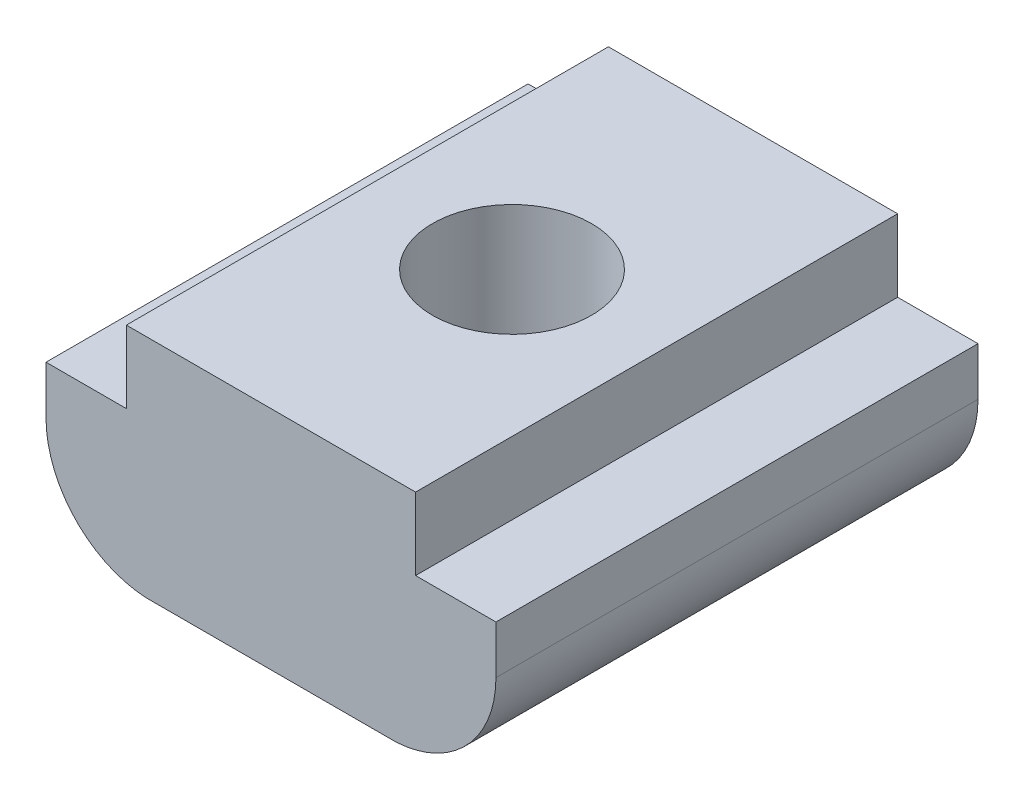
from build123d import *

# Parameters (mm, degrees)
EXTRUDE_1_DEPTH    = 10
HOLE_WIZARD_M4_1_D = 3.3


with BuildPart() as part:
    # 草图1 → 凸台-拉伸1 (new body)
    with BuildSketch(Plane.XY):
        with BuildLine():
            Line((3, 3), (-3, 3))
            Line((-3, 3), (-3, 1.5))
            Line((-3, 1.5), (-4.666746731, 1.5))
            Line((-4.666746731, 1.5), (-4.666746731, 0.5))
            ThreePointArc((-4.666746731, 0.5), (-4.068683171, -1.006990331), (-2.6, -1.69377241))
            Line((-2.6, -1.69377241), (2.6, -1.69377241))
            ThreePointArc((2.6, -1.69377241), (4.068683171, -1.006990331), (4.666746731, 0.5))
            Line((4.666746731, 0.5), (4.666746731, 1.5))
            Line((4.666746731, 1.5), (3, 1.5))
            Line((3, 1.5), (3, 3))
        make_face()
    extrude(amount=EXTRUDE_1_DEPTH)

    # M4 螺纹孔1 (through all)
    with Locations(Plane(origin=(0, 3, 0), x_dir=(1, 0, 0), z_dir=(0, 1, 0))):
        with Locations((0, -5)):
            Hole(HOLE_WIZARD_M4_1_D / 2)


with BuildPart() as part_1:
    # Move Body 1: moved
    add(part.part.moved(Location((0, 0, -5))))


solid = part_1.part
